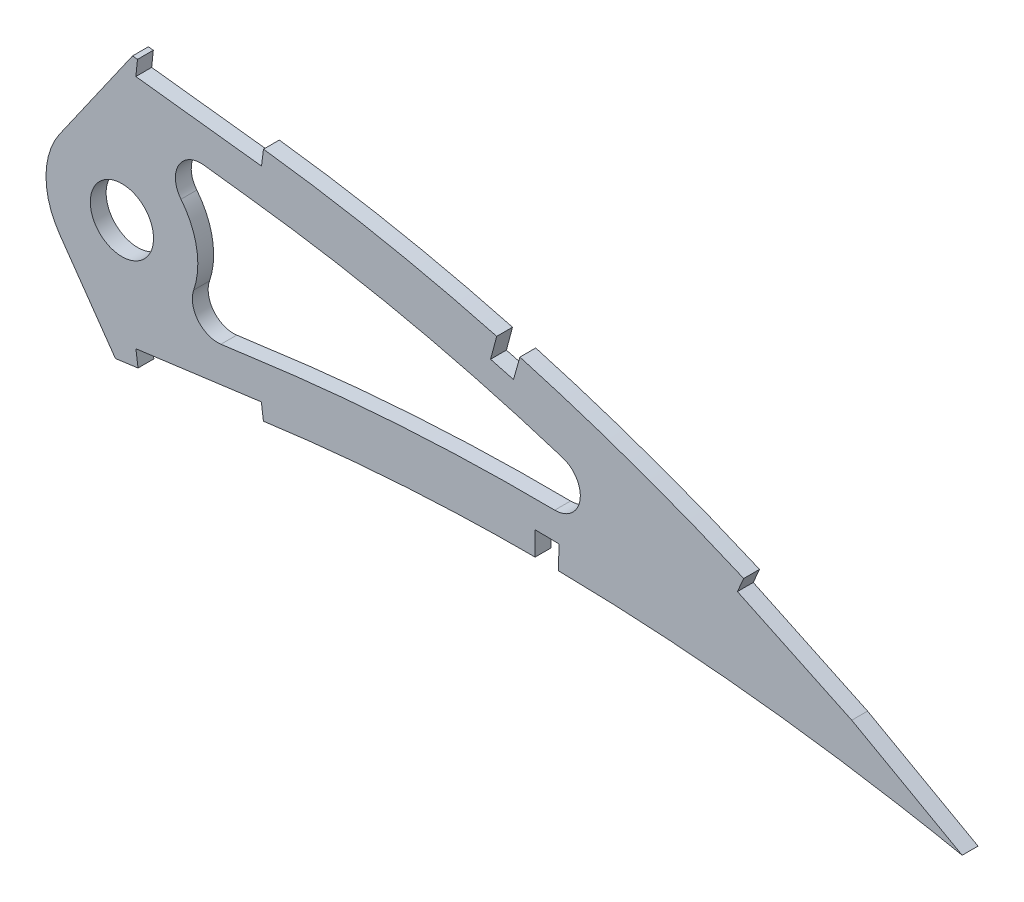
from build123d import *

# Parameters (mm, degrees)
BOSS_EXTRUDE1_DEPTH = 3.175
SKETCH3_R           = 6.35
CUT_EXTRUDE2_DEPTH  = 7.62
CUT_EXTRUDE3_DEPTH  = 495.005666426
FILLET1_R           = 5.08


with BuildPart() as part:
    # Sketch1 → Boss-Extrude1 (new body)
    with BuildSketch(Plane.XY):
        with BuildLine():
            Line((485.587399664, -0.75798934), (490.147728055, -1.684578565))
            Line((490.147728055, -1.684578565), (486.193791136, 0.75798934))
            add(Edge.make_bspline(
                [(486.193791136, 0.75798934), (486.156545565, 0.780998011), (486.007707871, 0.872943377), (485.672349582, 1.078647636), (485.113908292, 1.42125844), (484.332139179, 1.898395939), (483.327649378, 2.508793191), (482.099933618, 3.248176053), (480.649758178, 4.11414228), (478.977474042, 5.102596174), (477.083252712, 6.208909725), (474.9678154, 7.428600903), (472.631346146, 8.754764469), (470.074750091, 10.181981707), (467.298904376, 11.703464898), (464.304334104, 13.312342155), (461.092111509, 15.00042968), (457.663469746, 16.760467008), (454.019033833, 18.582734695), (450.160522056, 20.459648763), (446.08922006, 22.381851369), (441.806517314, 24.339086509), (437.314874314, 26.32337623), (432.615532729, 28.322383702), (427.711170694, 30.327448406), (422.603876177, 32.32715893), (417.296673201, 34.312408193), (411.791609239, 36.270335128), (406.092799427, 38.19238362), (400.203008281, 40.066067188), (394.126447785, 41.881210299), (387.866648542, 43.626044211), (381.42882875, 45.291620487), (374.81707141, 46.865809768), (368.036980395, 48.338075006), (361.093945075, 49.699552264), (353.993788332, 50.936649002), (346.7561854, 52.048400815), (339.497587697, 52.97319004), (332.253923966, 53.880196397), (325.021047815, 54.732245847), (317.699770737, 55.548201081), (310.297136308, 56.323468086), (302.820487344, 57.055622539), (295.277392798, 57.741504683), (287.675691417, 58.379102964), (280.022738792, 58.964804598), (272.326604726, 59.497707184), (264.594897726, 59.973125915), (256.835853078, 60.39070372), (249.05734719, 60.747528421), (241.267474913, 61.041141246), (233.474507978, 61.269769861), (225.686535745, 61.431223873), (217.911990598, 61.524488163), (210.158959277, 61.547014441), (202.435870244, 61.498399603), (194.750810842, 61.376974546), (187.112218127, 61.181076903), (179.528190462, 60.910341158), (172.006928802, 60.56488465), (164.556668167, 60.141814477), (157.185490761, 59.643826715), (149.90160498, 59.068829465), (142.713013757, 58.416669795), (135.627250794, 57.690066178), (128.652204991, 56.887042275), (121.795351463, 56.009883049), (115.064190238, 55.060308222), (108.466273869, 54.03780049), (102.008670179, 52.945313451), (95.69834878, 51.783964779), (89.541985966, 50.557159213), (83.546284377, 49.265216856), (77.717590812, 47.912013041), (72.061962755, 46.499905586), (66.585479912, 45.031479446), (61.293693841, 43.510258272), (56.191955701, 41.93969324), (51.286212878, 40.321510147), (46.580173058, 38.661844322), (42.079617138, 36.961873954), (37.787992638, 35.226836263), (33.71032906, 33.459100147), (29.849672544, 31.664054679), (26.210392495, 29.843743399), (22.795082621, 28.003266258), (19.607171667, 26.145445317), (16.649728276, 24.273731457), (13.923995526, 22.392872215), (11.433731376, 20.504048278), (9.179791317, 18.61203256), (7.163601692, 16.719706143), (5.388044474, 14.828372521), (3.853055719, 12.941362387), (2.560647106, 11.060170164), (1.511042845, 9.186575935), (0.706617001, 7.321940679), (0.14657185, 5.467313049), (-0.159993132, 3.625430402), (-0.236298987, 1.794816138), (-0.078648638, 0.597378122), (0, 0)],
                knots=[0, 0, 0, 0, 0.00025409, 0.001015373, 0.002283359, 0.004056577, 0.006330982, 0.009105274, 0.012374489, 0.016134023, 0.020379661, 0.025105976, 0.030306237, 0.035972206, 0.042099522, 0.048678064, 0.055701664, 0.063160184, 0.071045824, 0.079349827, 0.08806291, 0.097175757, 0.106678111, 0.116561573, 0.126814276, 0.137428301, 0.148393618, 0.15969976, 0.171338125, 0.183297699, 0.195569604, 0.208143556, 0.221011593, 0.234161831, 0.24758745, 0.261276822, 0.27522271, 0.289414144, 0.3037712, 0.317689226, 0.331784111, 0.346039677, 0.36044387, 0.374982721, 0.389640454, 0.404403317, 0.4192566, 0.434186749, 0.449177265, 0.464214782, 0.479284009, 0.49436974, 0.509457833, 0.524532346, 0.53957932, 0.554582984, 0.569529546, 0.584403417, 0.599190992, 0.613876838, 0.628447475, 0.642888675, 0.657186054, 0.671325546, 0.685294014, 0.699078147, 0.712665095, 0.726042645, 0.739197713, 0.752117586, 0.764792042, 0.777208152, 0.789355685, 0.80122396, 0.812803686, 0.824082909, 0.835054602, 0.845709571, 0.856037853, 0.866033834, 0.875688843, 0.884997719, 0.893953426, 0.902552897, 0.910789386, 0.918660734, 0.926166253, 0.933302626, 0.94007122, 0.94647478, 0.952517526, 0.958204819, 0.963546652, 0.9685566, 0.973249913, 0.977651041, 0.981787043, 0.985694226, 0.989415109, 0.993001157, 0.996508416, 1, 1, 1, 1], degree=3))
            add(Edge.make_bspline(
                [(0, 0), (0.124852845, -0.589388692), (0.375132337, -1.770874799), (1.055109044, -3.471725282), (1.954345773, -5.106735278), (3.091715472, -6.671561797), (4.459655687, -8.165777182), (6.055145152, -9.59093561), (7.876619233, -10.946270738), (9.92169391, -12.231165798), (12.187398396, -13.446984767), (14.671186068, -14.592971696), (17.370792198, -15.668768481), (20.283275494, -16.672937055), (23.405075375, -17.607006726), (26.733223776, -18.468701274), (30.263936284, -19.259225009), (33.993816996, -19.976560109), (37.918801514, -20.621435301), (42.034812323, -21.193489669), (46.337624631, -21.693081077), (50.82301706, -22.119161118), (55.4865531, -22.47264634), (60.323584549, -22.753771214), (65.329416188, -22.963427152), (70.499252954, -23.100817142), (75.828031579, -23.168083162), (81.310936338, -23.16623498), (86.942603653, -23.09477832), (92.718222737, -22.957660649), (98.632251256, -22.754013473), (104.679350026, -22.486301136), (110.854064483, -22.157217858), (117.150856575, -21.767879174), (123.564184912, -21.320010643), (130.088480981, -20.817203984), (136.717818035, -20.260713235), (143.446414433, -19.653782206), (150.268313286, -18.999449162), (157.177620607, -18.29978506), (164.168237687, -17.558081099), (171.233938121, -16.77674083), (178.368711149, -15.959932594), (185.566039209, -15.10913432), (192.819836156, -14.229203613), (200.123278023, -13.321821748), (207.470257634, -12.390483576), (214.854167095, -11.43957439), (222.268093801, -10.46898568), (229.705802131, -9.485632582), (237.16011938, -8.488705064), (244.624557097, -7.483330472), (252.092205531, -6.472633763), (259.555791095, -5.456925983), (267.00875308, -4.440416464), (274.444177456, -3.425895825), (281.854781181, -2.413456633), (289.233859631, -1.408131206), (296.573982386, -0.40979664), (303.868380953, 0.579523), (311.110065241, 1.55687475), (318.292203182, 2.521024953), (325.407385919, 3.471363717), (332.448454941, 4.408247897), (339.302915498, 5.303240759), (345.952856872, 6.204000824), (352.420688138, 6.942424504), (358.80798662, 7.572695641), (365.121387221, 8.089431053), (371.353308903, 8.500064921), (377.496611311, 8.807531395), (383.543972889, 9.016123146), (389.487754946, 9.132028332), (395.320533551, 9.158188245), (401.034347101, 9.102945563), (406.621764277, 8.970753247), (412.074986888, 8.767544827), (417.386407281, 8.500176147), (422.548480993, 8.175935919), (427.553458197, 7.799606866), (432.394364707, 7.379974648), (437.06373176, 6.923182232), (441.554389355, 6.434448486), (445.859785012, 5.92401425), (449.973027478, 5.395240442), (453.887929886, 4.85681652), (457.598190253, 4.314198878), (461.097932514, 3.774315295), (464.381658048, 3.242315892), (467.444062607, 2.72526199), (470.280349076, 2.227984348), (472.885595604, 1.755339323), (475.25618804, 1.313290259), (477.38744454, 0.904033197), (479.2765147, 0.534312721), (480.919885909, 0.205760173), (482.315149055, -0.076995438), (483.459867496, -0.312838295), (484.352302675, -0.497896754), (484.990691913, -0.632466588), (485.3743447, -0.712542465), (485.54480657, -0.748903783), (485.587399664, -0.75798934)],
                knots=[0, 0, 0, 0, 0.003638255, 0.007293231, 0.011028136, 0.014901081, 0.018963272, 0.023258475, 0.027820626, 0.032679082, 0.03785316, 0.043361875, 0.049214679, 0.055422346, 0.061988786, 0.068918036, 0.076211157, 0.083868392, 0.091887411, 0.100265912, 0.108999867, 0.118084529, 0.127514843, 0.13728527, 0.147387917, 0.157816481, 0.168563473, 0.179619128, 0.190977373, 0.202626974, 0.214560478, 0.226767249, 0.239236417, 0.251959004, 0.264923894, 0.278119703, 0.291536035, 0.30516028, 0.318980685, 0.332985499, 0.34716279, 0.361498603, 0.375980747, 0.390597192, 0.405332593, 0.420174823, 0.435109533, 0.450124276, 0.465203068, 0.480333154, 0.495500583, 0.510689775, 0.525887334, 0.541078314, 0.556247233, 0.571381785, 0.58646604, 0.601484516, 0.616424329, 0.631269423, 0.646006524, 0.660620684, 0.675098188, 0.689422858, 0.703581824, 0.716907564, 0.730009274, 0.742952128, 0.755725558, 0.768319952, 0.780724337, 0.792926528, 0.804916041, 0.816679084, 0.828203524, 0.8394749, 0.850481359, 0.861207697, 0.871639326, 0.881763414, 0.891563605, 0.901027364, 0.910138977, 0.918883976, 0.927249278, 0.935221104, 0.942784738, 0.949928188, 0.956638464, 0.962904204, 0.968712288, 0.974054485, 0.978918432, 0.983297218, 0.987180246, 0.990560674, 0.993433357, 0.995790626, 0.997629587, 0.998945816, 0.999736592, 1, 1, 1, 1], degree=3))
        make_face()
    extrude(amount=BOSS_EXTRUDE1_DEPTH)

    # Sketch3 → Cut-Extrude2 (cut)
    with BuildSketch(Plane(origin=(0, 0, 0), x_dir=(-1, 0, 0), z_dir=(0, 0, -1))):
        with Locations((-312.347728055, 26.255421435)):
            Circle(SKETCH3_R)
    extrude(amount=-CUT_EXTRUDE2_DEPTH, mode=Mode.SUBTRACT)

    # Sketch4 → Cut-Extrude3 (cut, through all)
    with BuildSketch(Plane.XY.offset(3.175)):
        with BuildLine():
            ThreePointArc((299.8638509, 17.514116545), (297.107728055, 26.255421435), (299.8638509, 34.996726325))
            Line((299.8638509, 34.996726325), (307.815975435, 46.353537128))
            Line((307.815975435, 46.353537128), (314.488133694, 55.882366646))
            add(Edge.make_bspline(
                [(314.488133694, 55.882366646), (313.098819132, 56.028454072), (309.217441166, 56.429197753), (302.820487344, 57.055622539), (295.277392798, 57.741504683), (287.675691417, 58.379102964), (280.022738792, 58.964804598), (272.326604726, 59.497707184), (264.594897726, 59.973125915), (256.835853078, 60.39070372), (249.05734719, 60.747528421), (241.267474913, 61.041141246), (233.474507978, 61.269769861), (225.686535745, 61.431223873), (217.911990598, 61.524488163), (210.158959277, 61.547014441), (202.435870244, 61.498399603), (194.750810842, 61.376974546), (187.112218127, 61.181076903), (179.528190462, 60.910341158), (172.006928802, 60.56488465), (164.556668167, 60.141814477), (157.185490761, 59.643826715), (149.90160498, 59.068829465), (142.713013757, 58.416669795), (135.627250794, 57.690066178), (128.652204991, 56.887042275), (121.795351463, 56.009883049), (115.064190238, 55.060308222), (108.466273869, 54.03780049), (102.008670179, 52.945313451), (95.69834878, 51.783964779), (89.541985966, 50.557159213), (83.546284377, 49.265216856), (77.717590812, 47.912013041), (72.061962755, 46.499905586), (66.585479912, 45.031479446), (61.293693841, 43.510258272), (56.191955701, 41.93969324), (51.286212878, 40.321510147), (46.580173058, 38.661844322), (42.079617138, 36.961873954), (37.787992638, 35.226836263), (33.71032906, 33.459100147), (29.849672544, 31.664054679), (26.210392495, 29.843743399), (22.795082621, 28.003266258), (19.607171667, 26.145445317), (16.649728276, 24.273731457), (13.923995526, 22.392872215), (11.433731376, 20.504048278), (9.179791317, 18.61203256), (7.163601692, 16.719706143), (5.388044474, 14.828372521), (3.853055719, 12.941362387), (2.560647106, 11.060170164), (1.511042845, 9.186575935), (0.706617001, 7.321940679), (0.14657185, 5.467313049), (-0.159993132, 3.625430402), (-0.236298987, 1.794816138), (-0.078648638, 0.597378122), (0, 0)],
                knots=[0.35233602, 0.35233602, 0.35233602, 0.35233602, 0.36044387, 0.374982721, 0.389640454, 0.404403317, 0.4192566, 0.434186749, 0.449177265, 0.464214782, 0.479284009, 0.49436974, 0.509457833, 0.524532346, 0.53957932, 0.554582984, 0.569529546, 0.584403417, 0.599190992, 0.613876838, 0.628447475, 0.642888675, 0.657186054, 0.671325546, 0.685294014, 0.699078147, 0.712665095, 0.726042645, 0.739197713, 0.752117586, 0.764792042, 0.777208152, 0.789355685, 0.80122396, 0.812803686, 0.824082909, 0.835054602, 0.845709571, 0.856037853, 0.866033834, 0.875688843, 0.884997719, 0.893953426, 0.902552897, 0.910789386, 0.918660734, 0.926166253, 0.933302626, 0.94007122, 0.94647478, 0.952517526, 0.958204819, 0.963546652, 0.9685566, 0.973249913, 0.977651041, 0.981787043, 0.985694226, 0.989415109, 0.993001157, 0.996508416, 1, 1, 1, 1], degree=3))
            add(Edge.make_bspline(
                [(0, 0), (0.124852845, -0.589388692), (0.375132337, -1.770874799), (1.055109044, -3.471725282), (1.954345773, -5.106735278), (3.091715472, -6.671561797), (4.459655687, -8.165777182), (6.055145152, -9.59093561), (7.876619233, -10.946270738), (9.92169391, -12.231165798), (12.187398396, -13.446984767), (14.671186068, -14.592971696), (17.370792198, -15.668768481), (20.283275494, -16.672937055), (23.405075375, -17.607006726), (26.733223776, -18.468701274), (30.263936284, -19.259225009), (33.993816996, -19.976560109), (37.918801514, -20.621435301), (42.034812323, -21.193489669), (46.337624631, -21.693081077), (50.82301706, -22.119161118), (55.4865531, -22.47264634), (60.323584549, -22.753771214), (65.329416188, -22.963427152), (70.499252954, -23.100817142), (75.828031579, -23.168083162), (81.310936338, -23.16623498), (86.942603653, -23.09477832), (92.718222737, -22.957660649), (98.632251256, -22.754013473), (104.679350026, -22.486301136), (110.854064483, -22.157217858), (117.150856575, -21.767879174), (123.564184912, -21.320010643), (130.088480981, -20.817203984), (136.717818035, -20.260713235), (143.446414433, -19.653782206), (150.268313286, -18.999449162), (157.177620607, -18.29978506), (164.168237687, -17.558081099), (171.233938121, -16.77674083), (178.368711149, -15.959932594), (185.566039209, -15.10913432), (192.819836156, -14.229203613), (200.123278023, -13.321821748), (207.470257634, -12.390483576), (214.854167095, -11.43957439), (222.268093801, -10.46898568), (229.705802131, -9.485632582), (237.16011938, -8.488705064), (244.624557097, -7.483330472), (252.092205531, -6.472633763), (259.555791095, -5.456925983), (267.00875308, -4.440416464), (274.444177456, -3.425895825), (281.854781181, -2.413456633), (289.233859631, -1.408131206), (296.573982386, -0.40979664), (303.839629429, 0.575623508), (308.657990094, 1.225937821), (311.044058633, 1.547125156)],
                knots=[0, 0, 0, 0, 0.003638255, 0.007293231, 0.011028136, 0.014901081, 0.018963272, 0.023258475, 0.027820626, 0.032679082, 0.03785316, 0.043361875, 0.049214679, 0.055422346, 0.061988786, 0.068918036, 0.076211157, 0.083868392, 0.091887411, 0.100265912, 0.108999867, 0.118084529, 0.127514843, 0.13728527, 0.147387917, 0.157816481, 0.168563473, 0.179619128, 0.190977373, 0.202626974, 0.214560478, 0.226767249, 0.239236417, 0.251959004, 0.264923894, 0.278119703, 0.291536035, 0.30516028, 0.318980685, 0.332985499, 0.34716279, 0.361498603, 0.375980747, 0.390597192, 0.405332593, 0.420174823, 0.435109533, 0.450124276, 0.465203068, 0.480333154, 0.495500583, 0.510689775, 0.525887334, 0.541078314, 0.556247233, 0.571381785, 0.58646604, 0.601484516, 0.616424329, 0.631269423, 0.645831036, 0.645831036, 0.645831036, 0.645831036], degree=3))
            Line((311.044058633, 1.547125156), (304.484880691, 10.91460206))
            Line((304.484880691, 10.91460206), (299.8638509, 17.514116545))
        make_face()
        with BuildLine():
            ThreePointArc((328.764508398, 44.057939686), (323.718114066, 41.472789893), (324.209352335, 35.824092683))
            ThreePointArc((324.209352335, 35.824092683), (327.314665257, 23.383420251), (319.825002945, 12.975814504))
            add(Edge.make_bspline(
                [(319.825002945, 12.975814504), (322.942820543, 13.392982967), (327.669877473, 14.024410231), (334.043339236, 14.862306396), (338.826488009, 15.492744251), (343.715664565, 16.151243809), (350.398623717, 16.952918213), (358.659540226, 17.783012705), (371.975290063, 18.792080277), (388.632726581, 19.430303401), (408.634763224, 19.217007594), (423.010853589, 18.377885686), (430.71684566, 17.722490027), (431.790737707, 17.62717887)],
                knots=[0.666430442, 0.666430442, 0.666430442, 0.666430442, 0.68544632, 0.695276122, 0.705105925, 0.714935727, 0.72476553, 0.744425135, 0.76408474, 0.80340395, 0.84272316, 0.88204237, 0.888412077, 0.888412077, 0.888412077, 0.888412077], degree=3))
            add(Edge.make_bspline(
                [(431.790737707, 17.62717887), (424.191477956, 20.8804212), (410.26123131, 26.282114189), (389.664440925, 32.773092285), (373.49731798, 36.840967689), (360.45479955, 39.506645362), (350.575577074, 41.228299699), (342.418796355, 42.368826827), (335.861477143, 43.188937517), (332.31248965, 43.629530132), (330.029806008, 43.906550774), (329.186314467, 44.00766024), (328.764508398, 44.057939686)],
                knots=[0.110005658, 0.110005658, 0.110005658, 0.110005658, 0.159341904, 0.19917738, 0.239012856, 0.258930594, 0.278848332, 0.298766071, 0.30872494, 0.317222758, 0.319712475, 0.322202192, 0.322202192, 0.322202192, 0.322202192], degree=3))
        make_face()
        with BuildLine():
            add(Edge.make_bspline(
                [(340.771051926, 52.809255955), (340.321486075, 52.866397518), (337.492730725, 53.224225716), (332.253923966, 53.880196397), (325.021047815, 54.732245847), (319.418146413, 55.356688369), (316.22734967, 55.698361537), (315.478729578, 55.7777567)],
                knots=[0.301141045, 0.301141045, 0.301141045, 0.301141045, 0.3037712, 0.317689226, 0.331784111, 0.346039677, 0.350408935, 0.350408935, 0.350408935, 0.350408935], degree=3))
            Line((315.478729578, 55.7777567), (315.143881725, 52.620463253))
            Line((315.143881725, 52.620463253), (340.370717936, 49.659596022))
            Line((340.370717936, 49.659596022), (340.771051926, 52.809255955))
        make_face()
        with BuildLine():
            Line((458.864665934, 12.571775826), (481.03757378, 0.181369955))
            add(Edge.make_bspline(
                [(481.03757378, 0.181369955), (481.491341815, 0.08995181), (482.326979612, -0.079432851), (483.459867496, -0.312838295), (484.352302675, -0.497896754), (484.990691913, -0.632466588), (485.3743447, -0.712542465), (485.54480657, -0.748903783), (485.587399664, -0.75798934)],
                knots=[0.990633731, 0.990633731, 0.990633731, 0.990633731, 0.993433357, 0.995790626, 0.997629587, 0.998945816, 0.999736592, 1, 1, 1, 1], degree=3))
            Line((485.587399664, -0.75798934), (490.147728055, -1.684578565))
            Line((490.147728055, -1.684578565), (486.193791136, 0.75798934))
            add(Edge.make_bspline(
                [(486.193791136, 0.75798934), (486.156545565, 0.780998011), (486.007707871, 0.872943377), (485.672349582, 1.078647636), (485.113908292, 1.42125844), (484.332139179, 1.898395939), (483.327649378, 2.508793191), (482.099933618, 3.248176053), (480.649758178, 4.11414228), (478.977474042, 5.102596174), (477.083252712, 6.208909725), (474.9678154, 7.428600903), (472.631346146, 8.754764469), (470.074750091, 10.181981707), (467.298904376, 11.703464898), (464.304334104, 13.312342155), (461.092111509, 15.00042968), (457.663469746, 16.760467008), (454.019033833, 18.582734695), (450.160522056, 20.459648763), (446.08922006, 22.381851369), (441.806517314, 24.339086509), (438.808273951, 25.663631556), (437.241501932, 26.342621223), (437.17697451, 26.370563129)],
                knots=[0, 0, 0, 0, 0.00025409, 0.001015373, 0.002283359, 0.004056577, 0.006330982, 0.009105274, 0.012374489, 0.016134023, 0.020379661, 0.025105976, 0.030306237, 0.035972206, 0.042099522, 0.048678064, 0.055701664, 0.063160184, 0.071045824, 0.079349827, 0.08806291, 0.097175757, 0.106678111, 0.107086222, 0.107086222, 0.107086222, 0.107086222], degree=3))
            Line((437.17697451, 26.370563129), (435.915330369, 23.456995031))
            Line((435.915330369, 23.456995031), (458.864665934, 12.571775826))
        make_face()
        with BuildLine():
            Line((315.158704756, 5.303615051), (315.580892501, 2.156809924))
            add(Edge.make_bspline(
                [(315.580892501, 2.156809924), (316.492147075, 2.279067419), (319.775884235, 2.719192684), (325.407385919, 3.471363717), (332.448454941, 4.408247897), (337.557936241, 5.075397303), (340.317929562, 5.444028001), (340.757486099, 5.502711912)],
                knots=[0.655059839, 0.655059839, 0.655059839, 0.655059839, 0.660620684, 0.675098188, 0.689422858, 0.703581824, 0.706263911, 0.706263911, 0.706263911, 0.706263911], degree=3))
            Line((340.757486099, 5.502711912), (340.337329046, 8.649788818))
            Line((340.337329046, 8.649788818), (315.158704756, 5.303615051))
        make_face()
        with BuildLine():
            add(Edge.make_bspline(
                [(392.24679827, 42.397573765), (390.803868257, 42.805366815), (389.252466711, 43.233052791), (387.698201472, 43.650087262), (387.592146791, 43.678490243)],
                knots=[0.19944107, 0.19944107, 0.19944107, 0.19944107, 0.208143556, 0.208780766, 0.208780766, 0.208780766, 0.208780766], degree=3))
            Line((387.592146791, 43.678490243), (386.360099239, 39.078113619))
            Line((386.360099239, 39.078113619), (390.960475863, 37.846066067))
            Line((390.960475863, 37.846066067), (392.24679827, 42.397573765))
        make_face()
        with BuildLine():
            add(Edge.make_bspline(
                [(395.301483032, 9.144612566), (395.320970567, 9.144563444), (396.890118785, 9.140495622), (398.459241636, 9.12737708), (400.008751567, 9.105526513)],
                knots=[0.81656122, 0.81656122, 0.81656122, 0.81656122, 0.816679084, 0.826051711, 0.826051711, 0.826051711, 0.826051711], degree=3))
            Line((400.008751567, 9.105526513), (400.07551444, 13.839945249))
            Line((400.07551444, 13.839945249), (395.313487893, 13.907097436))
            Line((395.313487893, 13.907097436), (395.301483032, 9.144612566))
        make_face()
    extrude(amount=-CUT_EXTRUDE3_DEPTH, mode=Mode.SUBTRACT)

    # Fillet1
    fillet1_edges = [part.edges().sort_by_distance(p)[0] for p in [
        (319.825002945, 12.975814504, 1.5875),
        (431.790737707, 17.62717887, 1.5875),
    ]]
    fillet(fillet1_edges, radius=FILLET1_R)


solid = part.part
